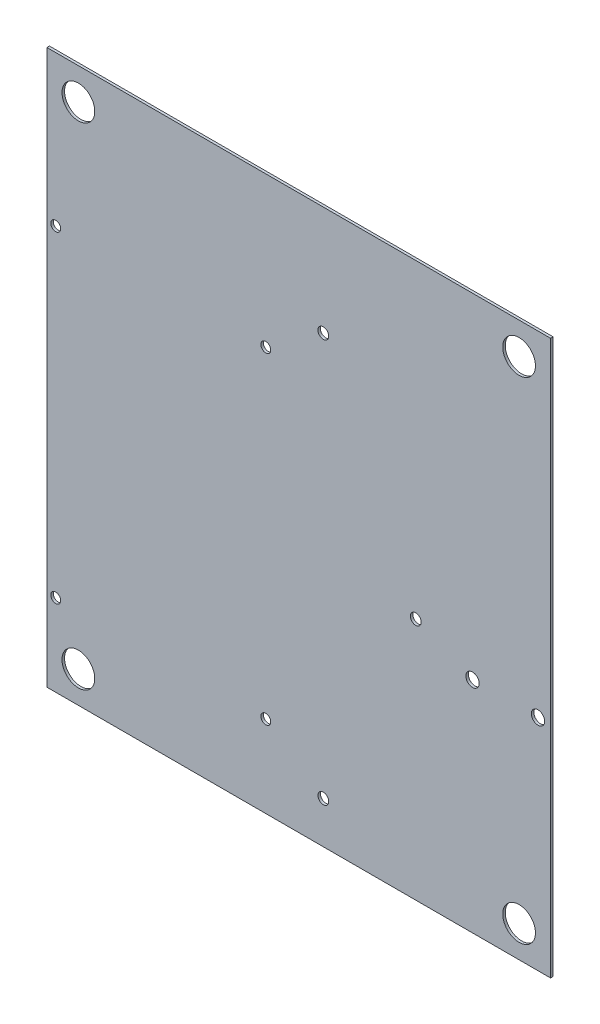
from build123d import *

# Parameters (mm, degrees)
SKETCH1_W           = 200
SKETCH1_H           = 220
SKETCH1_R           = 6.5
SKETCH1_R_2         = 2.15265
SKETCH1_R_3         = 1.97
SKETCH1_R_4         = 2.65
BOSS_EXTRUDE1_DEPTH = 1


with BuildPart() as part:
    # Sketch1 → Boss-Extrude1 (new body)
    with BuildSketch(Plane.XY):
        Rectangle(SKETCH1_W, SKETCH1_H)
        with Locations((-87.5, 97.5)):
            Circle(SKETCH1_R, mode=Mode.SUBTRACT)
        with Locations((87.5, 97.5)):
            Circle(SKETCH1_R, mode=Mode.SUBTRACT)
        with Locations((87.5, -97.5)):
            Circle(SKETCH1_R, mode=Mode.SUBTRACT)
        with Locations((-87.5, -97.5)):
            Circle(SKETCH1_R, mode=Mode.SUBTRACT)
        with Locations((9.76, -93.37)):
            Circle(SKETCH1_R_2, mode=Mode.SUBTRACT)
        with Locations((9.76, 66.65)):
            Circle(SKETCH1_R_2, mode=Mode.SUBTRACT)
        with Locations((46.46, -13.35)):
            Circle(SKETCH1_R_2, mode=Mode.SUBTRACT)
        with Locations((-96.495, 50.365)):
            Circle(SKETCH1_R_3, mode=Mode.SUBTRACT)
        with Locations((-13.085, 50.365)):
            Circle(SKETCH1_R_3, mode=Mode.SUBTRACT)
        with Locations((-13.085, -77.495)):
            Circle(SKETCH1_R_3, mode=Mode.SUBTRACT)
        with Locations((-96.495, -77.495)):
            Circle(SKETCH1_R_3, mode=Mode.SUBTRACT)
        with Locations((69, -22.92)):
            Circle(SKETCH1_R_4, mode=Mode.SUBTRACT)
        with Locations((95, -22.92)):
            Circle(SKETCH1_R_4, mode=Mode.SUBTRACT)
    extrude(amount=BOSS_EXTRUDE1_DEPTH)


solid = part.part
